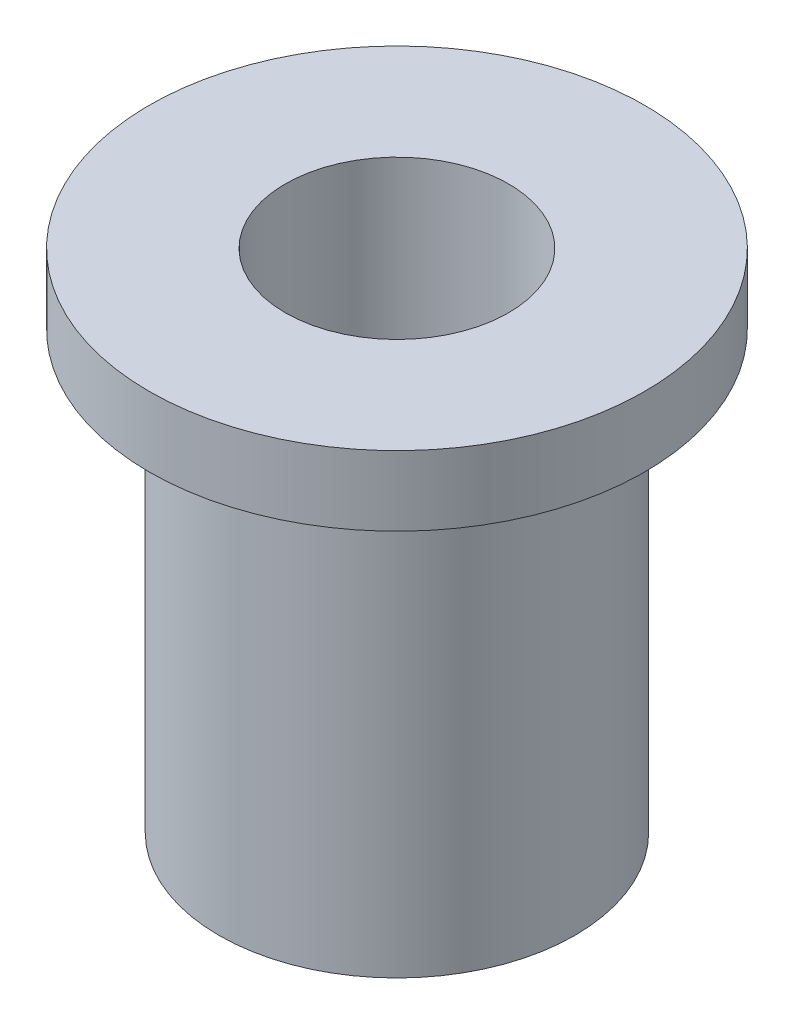
from build123d import *

# Parameters (mm, degrees)
SKETCH1_R           = 2.55
SKETCH1_R_2         = 1.6
BOSS_EXTRUDE1_DEPTH = 7.25
SKETCH2_R           = 3.55
SKETCH2_R_2         = 1.6
BOSS_EXTRUDE2_DEPTH = 1


with BuildPart() as part:
    # Sketch1 → Boss-Extrude1 (new body)
    with BuildSketch(Plane(origin=(0, 0, 0), x_dir=(1, 0, 0), z_dir=(0, 1, 0))):
        Circle(SKETCH1_R)
        Circle(SKETCH1_R_2, mode=Mode.SUBTRACT)
    extrude(amount=BOSS_EXTRUDE1_DEPTH)

    # Sketch2 → Boss-Extrude2 (add)
    with BuildSketch(Plane(origin=(0, 7.25, 0), x_dir=(1, 0, 0), z_dir=(0, 1, 0))):
        Circle(SKETCH2_R)
        Circle(SKETCH2_R_2, mode=Mode.SUBTRACT)
    extrude(amount=-BOSS_EXTRUDE2_DEPTH)


solid = part.part
